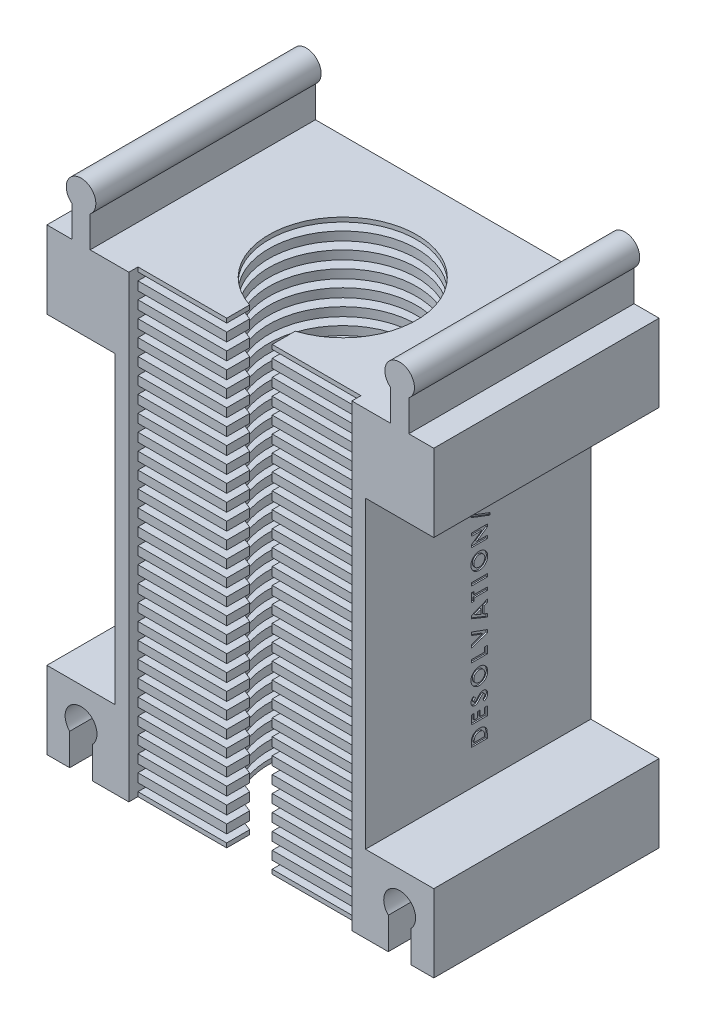
from build123d import *

# Parameters (mm, degrees)
ESQUISSE1_W              = 55
ESQUISSE1_H              = 106.55
BOSS_EXTRU_2_DEPTH       = 49.5
ESQUISSE6_W              = 49
ESQUISSE6_H              = 101.75
ENL_V_MAT_EXTRU_2_DEPTH  = 47
ESQUISSE7_W              = 49
ESQUISSE7_H              = 1.9
BOSS_EXTRU_3_DEPTH       = 45
ESQUISSE8_R              = 16.25
ENL_V_MAT_EXTRU_4_DEPTH  = 107.55
ESQUISSE9_W              = 10
ESQUISSE9_H              = 5.038353904
ENL_V_MAT_EXTRU_5_DEPTH  = 107.55
ESQUISSE11_W             = 55
ESQUISSE11_H             = 49.5
ENL_V_MAT_EXTRU_6_DEPTH  = 4.8
ESQUISSE14_W             = 15
ESQUISSE14_H             = 17.95
BOSS_EXTRU_5_DEPTH       = 49.5
ESQUISSE15_W             = 15
ESQUISSE15_H             = 17.95
BOSS_EXTRU_6_DEPTH       = 49.5
ESQUISSE16_W             = 15
ESQUISSE16_H             = 17
BOSS_EXTRU_7_DEPTH       = 49.5
ESQUISSE17_W             = 15
ESQUISSE17_H             = 17
BOSS_EXTRU_8_DEPTH       = 49.5
ENL_V_MAT_EXTRU_8_DEPTH  = 50.5
BOSS_EXTRU_9_DEPTH       = 49.5
ESQUISSE21_W             = 3.5
ESQUISSE21_H             = 0.628205128
ENL_V_MAT_EXTRU_9_DEPTH  = 0.3
ENL_V_MAT_EXTRU_10_DEPTH = 0.95
ESQUISSE22_W             = 5
ESQUISSE22_H             = 49.5
ENL_V_MAT_EXTRU_11_DEPTH = 0.95


with BuildPart() as part:
    # Esquisse1 → Boss.-Extru.2 (new body)
    with BuildSketch(Plane.XY):
        with Locations((7.352262443, -28.968325792)):
            Rectangle(ESQUISSE1_W, ESQUISSE1_H)
    extrude(amount=BOSS_EXTRU_2_DEPTH)

    # Esquisse6 → Enlèv. mat.-Extru.2 (cut)
    with BuildSketch(Plane.XY.offset(49.5)):
        with Locations((7.352262443, -31.368325792)):
            Rectangle(ESQUISSE6_W, ESQUISSE6_H)
    extrude(amount=-ENL_V_MAT_EXTRU_2_DEPTH, mode=Mode.SUBTRACT)

    # Esquisse7 → Boss.-Extru.3 (add)
    with BuildSketch(Plane.XY.offset(2.5)):
        with Locations((7.352262443, -81.293325792)):
            Rectangle(ESQUISSE7_W, ESQUISSE7_H)
        with Locations((7.352262443, -77.693325792)):
            Rectangle(ESQUISSE7_W, ESQUISSE7_H)
        with Locations((7.352262443, -74.093325792)):
            Rectangle(ESQUISSE7_W, ESQUISSE7_H)
        with Locations((7.352262443, -70.493325792)):
            Rectangle(ESQUISSE7_W, ESQUISSE7_H)
        with Locations((7.352262443, -66.893325792)):
            Rectangle(ESQUISSE7_W, ESQUISSE7_H)
        with Locations((7.352262443, -63.293325792)):
            Rectangle(ESQUISSE7_W, ESQUISSE7_H)
        with Locations((7.352262443, -59.693325792)):
            Rectangle(ESQUISSE7_W, ESQUISSE7_H)
        with Locations((7.352262443, -56.093325792)):
            Rectangle(ESQUISSE7_W, ESQUISSE7_H)
        with Locations((7.352262443, -52.493325792)):
            Rectangle(ESQUISSE7_W, ESQUISSE7_H)
        with Locations((7.352262443, -48.893325792)):
            Rectangle(ESQUISSE7_W, ESQUISSE7_H)
        with Locations((7.352262443, -45.293325792)):
            Rectangle(ESQUISSE7_W, ESQUISSE7_H)
        with Locations((7.352262443, -41.693325792)):
            Rectangle(ESQUISSE7_W, ESQUISSE7_H)
        with Locations((7.352262443, -38.093325792)):
            Rectangle(ESQUISSE7_W, ESQUISSE7_H)
        with Locations((7.352262443, -34.493325792)):
            Rectangle(ESQUISSE7_W, ESQUISSE7_H)
        with Locations((7.352262443, -30.893325792)):
            Rectangle(ESQUISSE7_W, ESQUISSE7_H)
        with Locations((7.352262443, -27.293325792)):
            Rectangle(ESQUISSE7_W, ESQUISSE7_H)
        with Locations((7.352262443, -23.693325792)):
            Rectangle(ESQUISSE7_W, ESQUISSE7_H)
        with Locations((7.352262443, -20.093325792)):
            Rectangle(ESQUISSE7_W, ESQUISSE7_H)
        with Locations((7.352262443, -16.493325792)):
            Rectangle(ESQUISSE7_W, ESQUISSE7_H)
        with Locations((7.352262443, -12.893325792)):
            Rectangle(ESQUISSE7_W, ESQUISSE7_H)
        with Locations((7.352262443, -9.293325792)):
            Rectangle(ESQUISSE7_W, ESQUISSE7_H)
        with Locations((7.352262443, -5.693325792)):
            Rectangle(ESQUISSE7_W, ESQUISSE7_H)
        with Locations((7.352262443, -2.093325792)):
            Rectangle(ESQUISSE7_W, ESQUISSE7_H)
        with Locations((7.352262443, 1.506674208)):
            Rectangle(ESQUISSE7_W, ESQUISSE7_H)
        with Locations((7.352262443, 5.106674208)):
            Rectangle(ESQUISSE7_W, ESQUISSE7_H)
        with Locations((7.352262443, 8.706674208)):
            Rectangle(ESQUISSE7_W, ESQUISSE7_H)
        with Locations((7.352262443, 12.306674208)):
            Rectangle(ESQUISSE7_W, ESQUISSE7_H)
        with Locations((7.352262443, 15.906674208)):
            Rectangle(ESQUISSE7_W, ESQUISSE7_H)
        with Locations((7.352262443, 19.506674208)):
            Rectangle(ESQUISSE7_W, ESQUISSE7_H)
    extrude(amount=BOSS_EXTRU_3_DEPTH)

    # Esquisse8 → Enlèv. mat.-Extru.4 (cut, through all)
    with BuildSketch(Plane.XZ.offset(82.243325792)):
        with Locations((7.352262443, 27)):
            Circle(ESQUISSE8_R)
    extrude(amount=-ENL_V_MAT_EXTRU_4_DEPTH, mode=Mode.SUBTRACT)

    # Esquisse9 → Enlèv. mat.-Extru.5 (cut, through all)
    with BuildSketch(Plane.XZ.offset(82.243325792)):
        with Locations((7.352262443, 44.980823048)):
            Rectangle(ESQUISSE9_W, ESQUISSE9_H)
    extrude(amount=-ENL_V_MAT_EXTRU_5_DEPTH, mode=Mode.SUBTRACT)

    # Esquisse11 → Enlèv. mat.-Extru.6 (cut)
    with BuildSketch(Plane(origin=(0, 24.306674208, 0), x_dir=(1, 0, 0), z_dir=(0, 1, 0))):
        with Locations((7.352262443, -24.75)):
            Rectangle(ESQUISSE11_W, ESQUISSE11_H)
    extrude(amount=-ENL_V_MAT_EXTRU_6_DEPTH, mode=Mode.SUBTRACT)

    # Esquisse14 → Boss.-Extru.5 (add)
    with BuildSketch(Plane.XY.offset(49.5)):
        with Locations((42.352262443, -73.268325792)):
            Rectangle(ESQUISSE14_W, ESQUISSE14_H)
    extrude(amount=-BOSS_EXTRU_5_DEPTH)

    # Esquisse15 → Boss.-Extru.6 (add)
    with BuildSketch(Plane.XY.offset(49.5)):
        with Locations((-27.647737557, -73.268325792)):
            Rectangle(ESQUISSE15_W, ESQUISSE15_H)
    extrude(amount=-BOSS_EXTRU_6_DEPTH)

    # Esquisse16 → Boss.-Extru.7 (add)
    with BuildSketch(Plane.XY.offset(49.5)):
        with Locations((42.352262443, 11.006674208)):
            Rectangle(ESQUISSE16_W, ESQUISSE16_H)
    extrude(amount=-BOSS_EXTRU_7_DEPTH)

    # Esquisse17 → Boss.-Extru.8 (add)
    with BuildSketch(Plane.XY.offset(49.5)):
        with Locations((-27.647737557, 11.006674208)):
            Rectangle(ESQUISSE17_W, ESQUISSE17_H)
    extrude(amount=-BOSS_EXTRU_8_DEPTH)

    # Esquisse18 → Enlèv. mat.-Extru.8 (cut, through all)
    with BuildSketch(Plane.XY.offset(49.5)):
        with BuildLine():
            Line((44.852262443, -74.343325792), (44.852262443, -82.243325792))
            Line((44.852262443, -82.243325792), (39.852262443, -82.243325792))
            Line((39.852262443, -82.243325792), (39.852262443, -74.343325792))
            ThreePointArc((39.852262443, -74.343325792), (42.352262443, -68.393836049), (44.852262443, -74.343325792))
        make_face()
        with BuildLine():
            Line((-30.147737557, -82.243325792), (-25.147737557, -82.243325792))
            Line((-25.147737557, -82.243325792), (-25.147737557, -74.343325792))
            ThreePointArc((-25.147737557, -74.343325792), (-27.647737557, -68.393836049), (-30.147737557, -74.343325792))
            Line((-30.147737557, -74.343325792), (-30.147737557, -82.243325792))
        make_face()
    extrude(amount=-ENL_V_MAT_EXTRU_8_DEPTH, mode=Mode.SUBTRACT)

    # Esquisse20 → Boss.-Extru.9 (add)
    with BuildSketch(Plane.XY.offset(49.5)):
        with BuildLine():
            Line((-29.647737557, 26.346674208), (-29.647737557, 19.506674208))
            Line((-29.647737557, 19.506674208), (-25.647737557, 19.506674208))
            Line((-25.647737557, 19.506674208), (-25.647737557, 26.346674208))
            ThreePointArc((-25.647737557, 26.346674208), (-27.647737557, 32.1584119), (-29.647737557, 26.346674208))
        make_face()
        with BuildLine():
            Line((40.352262443, 19.506674208), (40.352262443, 26.346674208))
            ThreePointArc((40.352262443, 26.346674208), (42.352262443, 32.1584119), (44.352262443, 26.346674208))
            Line((44.352262443, 26.346674208), (44.352262443, 19.506674208))
            Line((44.352262443, 19.506674208), (40.352262443, 19.506674208))
        make_face()
    extrude(amount=-BOSS_EXTRU_9_DEPTH)

    # Esquisse21 → Enlèv. mat.-Extru.9 (cut)
    with BuildSketch(Plane(origin=(34.852262443, 0, 0), x_dir=(0, 0, -1), z_dir=(1, 0, 0))):
        with BuildLine():
            Line((-26.25, -56.568966817), (-26.25, -55.777400311))
            add(Edge.make_bspline(
                [(-26.25, -55.777400311), (-26.249578594, -55.715687085), (-26.248764011, -55.59639472), (-26.239233964, -55.423588275), (-26.225241045, -55.262779541), (-26.203820297, -55.114334816), (-26.178974202, -54.977711122), (-26.145644783, -54.853944802), (-26.107640591, -54.742138404), (-26.062804681, -54.641206053), (-26.010558183, -54.549060361), (-25.952352997, -54.461566177), (-25.886064826, -54.378893855), (-25.812970397, -54.299883605), (-25.731733047, -54.225554968), (-25.643698202, -54.154670132), (-25.547589281, -54.088964674), (-25.445710659, -54.026452461), (-25.337630589, -53.969918483), (-25.224269024, -53.920607434), (-25.106355489, -53.87929927), (-24.983764318, -53.845734248), (-24.856902477, -53.818979051), (-24.72551397, -53.800258979), (-24.589720442, -53.788686044), (-24.4976865, -53.787512066), (-24.450921474, -53.786915535)],
                knots=[0, 0, 0, 0, 0.000185117, 0.000357834, 0.000519065, 0.000669183, 0.000807653, 0.000935374, 0.001053334, 0.001161611, 0.001266144, 0.001370762, 0.001476536, 0.001583695, 0.001693351, 0.00180657, 0.001922483, 0.002042366, 0.002164984, 0.002288073, 0.002412914, 0.002539466, 0.002669135, 0.002801605, 0.002937385, 0.003077654, 0.003077654, 0.003077654, 0.003077654], degree=3))
            add(Edge.make_bspline(
                [(-24.450921474, -53.786915535), (-24.384932979, -53.788477575), (-24.255030763, -53.791552542), (-24.064400757, -53.817454346), (-23.881662884, -53.859346333), (-23.708246589, -53.918250271), (-23.545696172, -53.991275386), (-23.396878133, -54.078512063), (-23.262591281, -54.178681211), (-23.143504152, -54.290615844), (-23.04114743, -54.41181382), (-22.953485402, -54.537762852), (-22.884360039, -54.669690389), (-22.840513664, -54.785935833), (-22.813270001, -54.886737915), (-22.797083391, -54.975231737), (-22.782639367, -55.075819688), (-22.769738179, -55.189168755), (-22.761139953, -55.315267782), (-22.755119024, -55.454138111), (-22.750668347, -55.605597536), (-22.75022862, -55.710790215), (-22.75, -55.765481241)],
                knots=[0, 0, 0, 0, 0.000197895, 0.000389568, 0.000575968, 0.000759549, 0.000938093, 0.001109685, 0.001275991, 0.00143967, 0.001598838, 0.001751113, 0.001899136, 0.002044464, 0.002122868, 0.002212109, 0.002314138, 0.002427722, 0.002554253, 0.002693218, 0.002844719, 0.003008787, 0.003008787, 0.003008787, 0.003008787], degree=3))
            Line((-22.75, -55.765481241), (-22.75, -56.568966817))
            Line((-22.75, -56.568966817), (-26.25, -56.568966817))
        make_face()
        with BuildLine():
            Line((-25.621794872, -55.940761689), (-23.378205128, -55.940761689))
            Line((-23.378205128, -55.940761689), (-23.378205128, -55.612636689))
            add(Edge.make_bspline(
                [(-23.378205128, -55.612636689), (-23.378394152, -55.573601622), (-23.378757652, -55.498535563), (-23.383752105, -55.390024754), (-23.391862503, -55.289884036), (-23.403859003, -55.197982239), (-23.418293863, -55.114108086), (-23.436147882, -55.038567527), (-23.457859729, -54.971211673), (-23.483447361, -54.91148508), (-23.512661318, -54.85695602), (-23.546774213, -54.806439255), (-23.584684458, -54.757684422), (-23.627472703, -54.711592604), (-23.674581701, -54.667992226), (-23.726251594, -54.627140464), (-23.782325449, -54.588492273), (-23.843099544, -54.553039619), (-23.907932147, -54.520642798), (-23.976195242, -54.491903186), (-24.04845732, -54.468073807), (-24.124041919, -54.448268286), (-24.20360709, -54.434114996), (-24.286563503, -54.422405848), (-24.373239826, -54.41636944), (-24.432217292, -54.415540981), (-24.462139423, -54.415120664)],
                knots=[0, 0, 0, 0, 0.000117096, 0.00022518, 0.000325793, 0.00041841, 0.000503133, 0.000581017, 0.00065108, 0.000715155, 0.0007757, 0.00083637, 0.000897801, 0.000960813, 0.001024815, 0.001090185, 0.001158251, 0.001228957, 0.001301074, 0.001375555, 0.001450937, 0.001529162, 0.001609745, 0.001693235, 0.001780402, 0.001870171, 0.001870171, 0.001870171, 0.001870171], degree=3))
            add(Edge.make_bspline(
                [(-24.462139423, -54.415120664), (-24.507993301, -54.415954791), (-24.597404811, -54.417581276), (-24.727617239, -54.433364792), (-24.850078276, -54.458796641), (-24.964473331, -54.495843815), (-25.071529664, -54.541402153), (-25.169867721, -54.599330531), (-25.261099367, -54.666109794), (-25.314608967, -54.718947546), (-25.341346154, -54.745349029)],
                knots=[0, 0, 0, 0, 0.000137507, 0.000268129, 0.000392852, 0.000512141, 0.000628325, 0.00074112, 0.000853862, 0.000966454, 0.000966454, 0.000966454, 0.000966454], degree=3))
            add(Edge.make_bspline(
                [(-25.341346154, -54.745349029), (-25.364130624, -54.771381223), (-25.410665325, -54.824549032), (-25.466425797, -54.917894233), (-25.515416837, -55.020755809), (-25.554261268, -55.135486926), (-25.584981101, -55.260978759), (-25.606167818, -55.397978738), (-25.619782177, -55.5457532), (-25.6211096, -55.648127904), (-25.621794872, -55.700978035)],
                knots=[0, 0, 0, 0, 0.000103595, 0.000211582, 0.000324802, 0.000444978, 0.000574215, 0.000711958, 0.000860493, 0.001019003, 0.001019003, 0.001019003, 0.001019003], degree=3))
            Line((-25.621794872, -55.700978035), (-25.621794872, -55.940761689))
        make_face(mode=Mode.SUBTRACT)
        Polygon((-26.25, -52.270248869), (-26.25, -50.385633484), (-25.621794872, -50.385633484), (-25.621794872, -51.642043741), (-24.948717949, -51.642043741), (-24.948717949, -50.385633484), (-24.320512821, -50.385633484), (-24.320512821, -51.642043741), (-23.378205128, -51.642043741), (-23.378205128, -50.385633484), (-22.75, -50.385633484), (-22.75, -52.270248869), align=None)
        with BuildLine():
            Line((-25.782351763, -47.074095023), (-25.352564103, -47.543846625))
            add(Edge.make_bspline(
                [(-25.352564103, -47.543846625), (-25.380948479, -47.56396877), (-25.435442524, -47.602600481), (-25.508411334, -47.665218455), (-25.57065916, -47.727553677), (-25.621925958, -47.790183645), (-25.661900244, -47.853663487), (-25.690202481, -47.91788301), (-25.708194481, -47.982478138), (-25.710434918, -48.025876092), (-25.711538462, -48.047252074)],
                knots=[0, 0, 0, 0, 0.000104333, 0.000200305, 0.000288057, 0.000368319, 0.000442638, 0.000512332, 0.000578316, 0.000642364, 0.000642364, 0.000642364, 0.000642364], degree=3))
            add(Edge.make_bspline(
                [(-25.711538462, -48.047252074), (-25.710859996, -48.067200818), (-25.709550059, -48.105716602), (-25.695874155, -48.160367956), (-25.673774631, -48.20948143), (-25.643247665, -48.251748774), (-25.606789609, -48.285751934), (-25.567978229, -48.312191421), (-25.525661045, -48.327555458), (-25.49663918, -48.329528504), (-25.482271635, -48.330505279)],
                knots=[0, 0, 0, 0, 5.9744e-05, 0.000115349, 0.000167746, 0.00022048, 0.000270574, 0.000316662, 0.00036057, 0.000403619, 0.000403619, 0.000403619, 0.000403619], degree=3))
            add(Edge.make_bspline(
                [(-25.482271635, -48.330505279), (-25.467703647, -48.329886982), (-25.438365745, -48.328641817), (-25.395367395, -48.316615224), (-25.353353002, -48.298487713), (-25.327776842, -48.281166136), (-25.314703526, -48.27231217)],
                knots=[0, 0, 0, 0, 4.3611e-05, 8.7826e-05, 0.000133031, 0.000180298, 0.000180298, 0.000180298, 0.000180298], degree=3))
            add(Edge.make_bspline(
                [(-25.314703526, -48.27231217), (-25.304570777, -48.264231681), (-25.281111756, -48.245523987), (-25.243396348, -48.21090352), (-25.198817605, -48.165697453), (-25.146449278, -48.111029204), (-25.085794161, -48.047089481), (-25.017865448, -47.972886999), (-24.943323803, -47.887879603), (-24.890772321, -47.828255945), (-24.86318109, -47.796951593)],
                knots=[0, 0, 0, 0, 3.8873e-05, 8.9997e-05, 0.000153455, 0.000229322, 0.000317108, 0.000417848, 0.000531096, 0.000656281, 0.000656281, 0.000656281, 0.000656281], degree=3))
            add(Edge.make_bspline(
                [(-24.86318109, -47.796951593), (-24.837708176, -47.767503382), (-24.789365877, -47.711616794), (-24.720638911, -47.632202055), (-24.659084447, -47.561955316), (-24.604241548, -47.501515443), (-24.558368712, -47.449076348), (-24.51864378, -47.406957294), (-24.486804547, -47.373355671), (-24.467551594, -47.354273887), (-24.459334936, -47.346130279)],
                knots=[0, 0, 0, 0, 0.00011681, 0.000221681, 0.000315075, 0.000396998, 0.000466519, 0.000524062, 0.000570675, 0.000605379, 0.000605379, 0.000605379, 0.000605379], degree=3))
            add(Edge.make_bspline(
                [(-24.459334936, -47.346130279), (-24.425893407, -47.31523371), (-24.361607045, -47.255839654), (-24.262008623, -47.17860103), (-24.164866042, -47.115310748), (-24.068591755, -47.06577726), (-23.970962887, -47.028711575), (-23.869873927, -47.002743909), (-23.764557336, -46.986955273), (-23.692829706, -46.985226056), (-23.656550481, -46.984351433)],
                knots=[0, 0, 0, 0, 0.000136539, 0.000262476, 0.000377607, 0.000483905, 0.000586645, 0.000690207, 0.000796501, 0.000905285, 0.000905285, 0.000905285, 0.000905285], degree=3))
            add(Edge.make_bspline(
                [(-23.656550481, -46.984351433), (-23.62120206, -46.984977938), (-23.551847141, -46.986207165), (-23.450356547, -47.001262831), (-23.353225654, -47.022731334), (-23.261511331, -47.055925385), (-23.173708316, -47.096382164), (-23.091183556, -47.14710033), (-23.013104683, -47.206662795), (-22.940856727, -47.27492696), (-22.87532825, -47.350448565), (-22.816876988, -47.43140365), (-22.76900145, -47.518893919), (-22.728000136, -47.611176844), (-22.698822842, -47.709937255), (-22.675868152, -47.813375185), (-22.662419885, -47.922565757), (-22.660987959, -47.997202332), (-22.66025641, -48.035333003)],
                knots=[0, 0, 0, 0, 0.000105953, 0.000207884, 0.000307206, 0.000403889, 0.000499869, 0.000596786, 0.000693825, 0.000794014, 0.0008944, 0.000993427, 0.001092919, 0.001193084, 0.001295767, 0.001401245, 0.001510733, 0.001625093, 0.001625093, 0.001625093, 0.001625093], degree=3))
            add(Edge.make_bspline(
                [(-22.66025641, -48.035333003), (-22.660787067, -48.065267424), (-22.661838073, -48.124554745), (-22.670430813, -48.211932456), (-22.684268419, -48.296316378), (-22.704207169, -48.377560965), (-22.729126286, -48.456301852), (-22.76093787, -48.531771488), (-22.797508368, -48.604512241), (-22.839623573, -48.674374584), (-22.888564784, -48.740917968), (-22.94241612, -48.806007246), (-23.003786402, -48.867498389), (-23.071484125, -48.926769458), (-23.145924483, -48.983055602), (-23.225977896, -49.038278515), (-23.31315656, -49.089961723), (-23.374312024, -49.121889558), (-23.405548878, -49.138197587)],
                knots=[0, 0, 0, 0, 8.9787e-05, 0.000177831, 0.000263126, 0.00034611, 0.000428593, 0.000510624, 0.000591521, 0.000672684, 0.000755006, 0.00083912, 0.000925881, 0.001015317, 0.001108851, 0.001205697, 0.00130694, 0.001412645, 0.001412645, 0.001412645, 0.001412645], degree=3))
            Line((-23.405548878, -49.138197587), (-23.737179487, -48.585713612))
            add(Edge.make_bspline(
                [(-23.737179487, -48.585713612), (-23.701721473, -48.565314802), (-23.63374543, -48.526208538), (-23.542411001, -48.459939319), (-23.464198182, -48.392049887), (-23.400489388, -48.3209707), (-23.350432751, -48.247566053), (-23.314658806, -48.171481385), (-23.292514774, -48.092663241), (-23.289810476, -48.038975902), (-23.288461538, -48.012195984)],
                knots=[0, 0, 0, 0, 0.000122646, 0.000235123, 0.000337949, 0.000432798, 0.000520693, 0.0006035, 0.000684117, 0.000764351, 0.000764351, 0.000764351, 0.000764351], degree=3))
            add(Edge.make_bspline(
                [(-23.288461538, -48.012195984), (-23.289563154, -47.984956973), (-23.291700449, -47.932109325), (-23.311441996, -47.856676069), (-23.342437673, -47.787516005), (-23.38666423, -47.727734556), (-23.437708399, -47.677115394), (-23.494497371, -47.639755546), (-23.555941668, -47.616285839), (-23.598624918, -47.613804521), (-23.620092147, -47.612556561)],
                knots=[0, 0, 0, 0, 8.1575e-05, 0.000158267, 0.000232307, 0.000307618, 0.000380007, 0.000446905, 0.00051034, 0.000574526, 0.000574526, 0.000574526, 0.000574526], degree=3))
            add(Edge.make_bspline(
                [(-23.620092147, -47.612556561), (-23.640063911, -47.613709001), (-23.680634636, -47.616050074), (-23.74095678, -47.633293689), (-23.801251492, -47.66025072), (-23.850706845, -47.692142789), (-23.892114472, -47.724596963), (-23.927992307, -47.755630472), (-23.967631034, -47.793421078), (-24.011080516, -47.837872959), (-24.058723248, -47.88839879), (-24.110554566, -47.945041133), (-24.166117898, -48.008448602), (-24.20396709, -48.053265126), (-24.223758013, -48.076699189)],
                knots=[0, 0, 0, 0, 5.9859e-05, 0.000121597, 0.000186877, 0.000257482, 0.000297452, 0.000344677, 0.000399728, 0.000461701, 0.000531137, 0.000608059, 0.000692021, 0.000784039, 0.000784039, 0.000784039, 0.000784039], degree=3))
            add(Edge.make_bspline(
                [(-24.223758013, -48.076699189), (-24.261450785, -48.121248313), (-24.333794625, -48.206751566), (-24.440644621, -48.327577916), (-24.540504245, -48.436455362), (-24.634614437, -48.532434437), (-24.721216561, -48.616767369), (-24.801079437, -48.688790932), (-24.874765535, -48.748119143), (-24.962626851, -48.809701418), (-25.0687399, -48.868922242), (-25.196325337, -48.920201939), (-25.324023034, -48.953158574), (-25.4098701, -48.956879161), (-25.452123397, -48.958710407)],
                knots=[0, 0, 0, 0, 0.000175062, 0.000335996, 0.000483855, 0.000618216, 0.0007392, 0.000846451, 0.000940727, 0.001022807, 0.00116813, 0.001304054, 0.001434653, 0.001561236, 0.001561236, 0.001561236, 0.001561236], degree=3))
            add(Edge.make_bspline(
                [(-25.452123397, -48.958710407), (-25.482088506, -48.957951198), (-25.54112299, -48.956455475), (-25.627924828, -48.943113858), (-25.711680407, -48.923173207), (-25.792088406, -48.894217673), (-25.86903224, -48.856622348), (-25.94294889, -48.811018754), (-26.013062404, -48.756339157), (-26.080062459, -48.695502211), (-26.140663498, -48.627665077), (-26.194122447, -48.55547558), (-26.239518366, -48.479250328), (-26.275959011, -48.398695632), (-26.304885676, -48.314469448), (-26.325149965, -48.226358987), (-26.337265806, -48.134529777), (-26.338907372, -48.072062067), (-26.33974359, -48.040240856)],
                knots=[0, 0, 0, 0, 8.9842e-05, 0.000176999, 0.000262874, 0.000347814, 0.000432791, 0.000519374, 0.000607862, 0.00069917, 0.000790526, 0.000880272, 0.00096829, 0.00105614, 0.00114505, 0.001235018, 0.00132694, 0.001422385, 0.001422385, 0.001422385, 0.001422385], degree=3))
            add(Edge.make_bspline(
                [(-26.33974359, -48.040240856), (-26.338235058, -47.999002941), (-26.335229901, -47.916852628), (-26.311729417, -47.795391603), (-26.274775458, -47.676751209), (-26.230185096, -47.581156052), (-26.187011968, -47.50507503), (-26.147199435, -47.446819861), (-26.101765707, -47.387195621), (-26.049430261, -47.327125219), (-25.991909725, -47.265150458), (-25.927878206, -47.20218695), (-25.857994416, -47.137563989), (-25.808007695, -47.095621971), (-25.782351763, -47.074095023)],
                knots=[0, 0, 0, 0, 0.000123638, 0.0002463, 0.000369811, 0.000495611, 0.000561878, 0.000632077, 0.000707101, 0.000786646, 0.000870979, 0.000960715, 0.001055985, 0.001156444, 0.001156444, 0.001156444, 0.001156444], degree=3))
        make_face()
        with BuildLine():
            add(Edge.make_bspline(
                [(-26.33974359, -43.822853035), (-26.338167721, -43.762001434), (-26.3350566, -43.641866592), (-26.309132442, -43.465188325), (-26.266869189, -43.294938823), (-26.208203575, -43.13113496), (-26.131234536, -42.974520936), (-26.039491395, -42.823570349), (-25.928986383, -42.680195073), (-25.803655216, -42.544890444), (-25.667274317, -42.419884252), (-25.520441097, -42.311593951), (-25.366840026, -42.21899487), (-25.205888991, -42.142814829), (-25.037039251, -42.084298219), (-24.860994412, -42.043414326), (-24.677706796, -42.017114909), (-24.552909074, -42.014092592), (-24.489483173, -42.012556561)],
                knots=[0, 0, 0, 0, 0.000182486, 0.000360268, 0.000534396, 0.00070805, 0.00088114, 0.00105706, 0.001237116, 0.001423178, 0.0016098, 0.001791254, 0.001969572, 0.002147089, 0.002324474, 0.002504569, 0.0026886, 0.00287879, 0.00287879, 0.00287879, 0.00287879], degree=3))
            add(Edge.make_bspline(
                [(-24.489483173, -42.012556561), (-24.426772131, -42.014192899), (-24.30319801, -42.017417355), (-24.121596661, -42.042335582), (-23.947447913, -42.083934104), (-23.780397792, -42.141298905), (-23.621288648, -42.216230374), (-23.469456335, -42.307245168), (-23.325421581, -42.415302063), (-23.189791309, -42.537812006), (-23.06584061, -42.671849774), (-22.95732277, -42.814611152), (-22.86539022, -42.964394772), (-22.789684465, -43.121083325), (-22.73257561, -43.285805914), (-22.689870401, -43.456703157), (-22.665166628, -43.635165027), (-22.66190961, -43.756405724), (-22.66025641, -43.817945183)],
                knots=[0, 0, 0, 0, 0.000188089, 0.000370635, 0.000548684, 0.000724515, 0.000899532, 0.001075324, 0.001254672, 0.001438843, 0.001622923, 0.001801572, 0.00197593, 0.002149347, 0.002322529, 0.002498019, 0.002677092, 0.002861679, 0.002861679, 0.002861679, 0.002861679], degree=3))
            add(Edge.make_bspline(
                [(-22.66025641, -43.817945183), (-22.66172221, -43.882312928), (-22.664602305, -44.00878675), (-22.691759654, -44.1939277), (-22.733164649, -44.371055921), (-22.793109119, -44.539686079), (-22.870998612, -44.699687081), (-22.965044231, -44.851776466), (-23.077062596, -44.994810385), (-23.203675043, -45.128312064), (-23.342252759, -45.249250819), (-23.488638503, -45.356006675), (-23.641725246, -45.446056684), (-23.801581713, -45.51940547), (-23.967215196, -45.577230646), (-24.13963425, -45.618019753), (-24.318425406, -45.642114848), (-24.439863931, -45.645471155), (-24.501402244, -45.647171946)],
                knots=[0, 0, 0, 0, 0.000192992, 0.000379203, 0.000560143, 0.000737993, 0.000914849, 0.001093067, 0.001273424, 0.001458907, 0.001644244, 0.001824454, 0.002001698, 0.002176124, 0.002351292, 0.002527132, 0.002706806, 0.002891392, 0.002891392, 0.002891392, 0.002891392], degree=3))
            add(Edge.make_bspline(
                [(-24.501402244, -45.647171946), (-24.542801939, -45.646637984), (-24.625077116, -45.64557682), (-24.747005781, -45.632800024), (-24.866550437, -45.61439328), (-24.983253879, -45.58721462), (-25.098077566, -45.553983661), (-25.209998546, -45.511492182), (-25.31977582, -45.46250229), (-25.426179008, -45.405860667), (-25.527982507, -45.34182707), (-25.626061507, -45.273445763), (-25.717849216, -45.198112983), (-25.804324601, -45.117368295), (-25.885156419, -45.030941799), (-25.960260646, -44.938659263), (-26.030496839, -44.841183532), (-26.094932582, -44.738505642), (-26.151890013, -44.631385042), (-26.202895691, -44.522185532), (-26.244766818, -44.410453326), (-26.279240778, -44.29684322), (-26.306944788, -44.18151578), (-26.325356866, -44.063554362), (-26.338128579, -43.943961559), (-26.339203975, -43.863318348), (-26.33974359, -43.822853035)],
                knots=[0, 0, 0, 0, 0.000124148, 0.000246724, 0.000367409, 0.000486805, 0.000605941, 0.000725748, 0.00084563, 0.000966388, 0.001087007, 0.001206249, 0.001324841, 0.0014429, 0.001560959, 0.001679551, 0.001799606, 0.001921192, 0.002042899, 0.002163361, 0.002282513, 0.002400505, 0.002519378, 0.002637986, 0.002758469, 0.002879813, 0.002879813, 0.002879813, 0.002879813], degree=3))
        make_face()
        with BuildLine():
            add(Edge.make_bspline(
                [(-25.711538462, -43.832668741), (-25.710439594, -43.873621987), (-25.708270869, -43.954447307), (-25.691748119, -44.073003332), (-25.66535941, -44.186821303), (-25.627135687, -44.295270281), (-25.578486588, -44.398820295), (-25.5195821, -44.497654906), (-25.448397447, -44.590405459), (-25.368754215, -44.678308693), (-25.280013352, -44.757714801), (-25.184912425, -44.827872602), (-25.083610251, -44.886583381), (-24.977047904, -44.935754027), (-24.864027118, -44.972768625), (-24.745433197, -44.999133013), (-24.621061798, -45.015794323), (-24.536277978, -45.017894501), (-24.492988782, -45.018966817)],
                knots=[0, 0, 0, 0, 0.000122824, 0.000242406, 0.000358388, 0.000472807, 0.000586661, 0.000701131, 0.000817238, 0.000936842, 0.001056496, 0.001173871, 0.001290754, 0.001407153, 0.001525327, 0.001646775, 0.001771221, 0.00190105, 0.00190105, 0.00190105, 0.00190105], degree=3))
            add(Edge.make_bspline(
                [(-24.492988782, -45.018966817), (-24.445016002, -45.017541828), (-24.350997301, -45.014749085), (-24.213821902, -44.995189856), (-24.084150974, -44.961427616), (-23.962628361, -44.913548335), (-23.848569642, -44.852866041), (-23.742617566, -44.778538736), (-23.64427387, -44.690578429), (-23.586841652, -44.622852092), (-23.557692308, -44.588478035)],
                knots=[0, 0, 0, 0, 0.000143901, 0.000282022, 0.000414667, 0.000544995, 0.00067297, 0.000801345, 0.000932411, 0.001067493, 0.001067493, 0.001067493, 0.001067493], degree=3))
            add(Edge.make_bspline(
                [(-23.557692308, -44.588478035), (-23.536158968, -44.560316757), (-23.493577439, -44.504628678), (-23.439000474, -44.41573838), (-23.392222571, -44.324198877), (-23.354426578, -44.229319388), (-23.324696886, -44.131300293), (-23.303877671, -44.030155034), (-23.290811814, -43.926026926), (-23.289250196, -43.855610619), (-23.288461538, -43.820048548)],
                knots=[0, 0, 0, 0, 0.000106293, 0.000210192, 0.000312412, 0.000414354, 0.000516162, 0.000619291, 0.000723822, 0.000830475, 0.000830475, 0.000830475, 0.000830475], degree=3))
            add(Edge.make_bspline(
                [(-23.288461538, -43.820048548), (-23.289571354, -43.779800318), (-23.291754951, -43.70061066), (-23.308051007, -43.584249849), (-23.335754907, -43.472827233), (-23.373360596, -43.365296451), (-23.423815369, -43.263147933), (-23.483422698, -43.164756684), (-23.555069551, -43.071837973), (-23.636390935, -42.984425718), (-23.725443642, -42.904248434), (-23.820575808, -42.833516927), (-23.920902252, -42.773840352), (-24.026406378, -42.72504465), (-24.136972237, -42.686821477), (-24.25293853, -42.660723853), (-24.373776907, -42.643935536), (-24.456006023, -42.641832868), (-24.497896635, -42.640761689)],
                knots=[0, 0, 0, 0, 0.000120723, 0.000237527, 0.000351629, 0.000464725, 0.000578551, 0.000692784, 0.000809316, 0.00092987, 0.001050514, 0.001168305, 0.00128494, 0.001400065, 0.00151647, 0.001635184, 0.001756155, 0.001881781, 0.001881781, 0.001881781, 0.001881781], degree=3))
            add(Edge.make_bspline(
                [(-24.497896635, -42.640761689), (-24.539547888, -42.641866123), (-24.621532028, -42.644040033), (-24.742037961, -42.660428234), (-24.857356876, -42.68767306), (-24.967786038, -42.726178708), (-25.07390519, -42.774148733), (-25.17479331, -42.83440707), (-25.270363111, -42.90564759), (-25.360046419, -42.986567956), (-25.442465159, -43.074630313), (-25.513988235, -43.169177871), (-25.576139881, -43.267560561), (-25.624826882, -43.372036945), (-25.663615736, -43.480469217), (-25.692180398, -43.593519118), (-25.708154796, -43.711614809), (-25.710400519, -43.791957751), (-25.711538462, -43.832668741)],
                knots=[0, 0, 0, 0, 0.000124926, 0.000245897, 0.000364088, 0.00047983, 0.000596229, 0.000712864, 0.000831635, 0.000953269, 0.001074815, 0.001192886, 0.001308453, 0.00142324, 0.001537892, 0.001653524, 0.001772411, 0.001894535, 0.001894535, 0.001894535, 0.001894535], degree=3))
        make_face(mode=Mode.SUBTRACT)
        Polygon((-26.25, -40.495889894), (-26.25, -39.867684766), (-23.378205128, -39.867684766), (-23.378205128, -38.880505279), (-22.75, -38.880505279), (-22.75, -40.495889894), align=None)
        Polygon((-26.25, -37.745248869), (-26.25, -37.074275311), (-23.763822115, -36.174736048), (-26.25, -35.27309342), (-26.25, -34.604223228), (-22.75, -35.873253676), (-22.75, -36.478321785), align=None)
        Polygon((-26.25, -32.077240055), (-26.25, -31.494607843), (-22.75, -30.081146305), (-22.75, -30.752119862), (-23.467948718, -31.024155119), (-23.467948718, -32.549095023), (-22.75, -32.821130279), (-22.75, -33.491402715), align=None)
        Polygon((-25.311197917, -31.78627451), (-24.096153846, -32.310713612), (-24.096153846, -31.261835407), align=None, mode=Mode.SUBTRACT)
        Polygon((-26.25, -29.035633484), (-26.25, -27.1510181), (-25.621794872, -27.1510181), (-25.621794872, -27.779223228), (-22.75, -27.779223228), (-22.75, -28.407428356), (-25.621794872, -28.407428356), (-25.621794872, -29.035633484), align=None)
        with Locations((-24.5, -25.544607843)):
            Rectangle(ESQUISSE21_W, ESQUISSE21_H)
        with BuildLine():
            add(Edge.make_bspline(
                [(-26.33974359, -21.889519702), (-26.338167721, -21.828668101), (-26.3350566, -21.708533258), (-26.309132442, -21.531854992), (-26.266869189, -21.36160549), (-26.208203575, -21.197801627), (-26.131234536, -21.041187603), (-26.039491395, -20.890237016), (-25.928986383, -20.74686174), (-25.803655216, -20.611557111), (-25.667274317, -20.486550918), (-25.520441097, -20.378260618), (-25.366840026, -20.285661537), (-25.205888991, -20.209481496), (-25.037039251, -20.150964886), (-24.860994412, -20.110080992), (-24.677706796, -20.083781576), (-24.552909074, -20.080759259), (-24.489483173, -20.079223228)],
                knots=[0, 0, 0, 0, 0.000182486, 0.000360268, 0.000534396, 0.00070805, 0.00088114, 0.00105706, 0.001237116, 0.001423178, 0.0016098, 0.001791254, 0.001969572, 0.002147089, 0.002324474, 0.002504569, 0.0026886, 0.00287879, 0.00287879, 0.00287879, 0.00287879], degree=3))
            add(Edge.make_bspline(
                [(-24.489483173, -20.079223228), (-24.426772131, -20.080859566), (-24.30319801, -20.084084022), (-24.121596661, -20.109002249), (-23.947447913, -20.150600771), (-23.780397792, -20.207965572), (-23.621288648, -20.28289704), (-23.469456335, -20.373911835), (-23.325421581, -20.481968729), (-23.189791309, -20.604478673), (-23.06584061, -20.738516441), (-22.95732277, -20.881277818), (-22.86539022, -21.031061438), (-22.789684465, -21.187749992), (-22.73257561, -21.352472581), (-22.689870401, -21.523369824), (-22.665166628, -21.701831693), (-22.66190961, -21.82307239), (-22.66025641, -21.88461185)],
                knots=[0, 0, 0, 0, 0.000188089, 0.000370635, 0.000548684, 0.000724515, 0.000899532, 0.001075324, 0.001254672, 0.001438843, 0.001622923, 0.001801572, 0.00197593, 0.002149347, 0.002322529, 0.002498019, 0.002677092, 0.002861679, 0.002861679, 0.002861679, 0.002861679], degree=3))
            add(Edge.make_bspline(
                [(-22.66025641, -21.88461185), (-22.66172221, -21.948979595), (-22.664602305, -22.075453417), (-22.691759654, -22.260594366), (-22.733164649, -22.437722588), (-22.793109119, -22.606352745), (-22.870998612, -22.766353748), (-22.965044231, -22.918443132), (-23.077062596, -23.061477051), (-23.203675043, -23.19497873), (-23.342252759, -23.315917486), (-23.488638503, -23.422673342), (-23.641725246, -23.512723351), (-23.801581713, -23.586072137), (-23.967215196, -23.643897313), (-24.13963425, -23.68468642), (-24.318425406, -23.708781515), (-24.439863931, -23.712137822), (-24.501402244, -23.713838612)],
                knots=[0, 0, 0, 0, 0.000192992, 0.000379203, 0.000560143, 0.000737993, 0.000914849, 0.001093067, 0.001273424, 0.001458907, 0.001644244, 0.001824454, 0.002001698, 0.002176124, 0.002351292, 0.002527132, 0.002706806, 0.002891392, 0.002891392, 0.002891392, 0.002891392], degree=3))
            add(Edge.make_bspline(
                [(-24.501402244, -23.713838612), (-24.542801939, -23.71330465), (-24.625077116, -23.712243487), (-24.747005781, -23.699466691), (-24.866550437, -23.681059946), (-24.983253879, -23.653881286), (-25.098077566, -23.620650328), (-25.209998546, -23.578158849), (-25.31977582, -23.529168957), (-25.426179008, -23.472527334), (-25.527982507, -23.408493737), (-25.626061507, -23.34011243), (-25.717849216, -23.26477965), (-25.804324601, -23.184034962), (-25.885156419, -23.097608466), (-25.960260646, -23.00532593), (-26.030496839, -22.907850198), (-26.094932582, -22.805172309), (-26.151890013, -22.698051708), (-26.202895691, -22.588852199), (-26.244766818, -22.477119992), (-26.279240778, -22.363509887), (-26.306944788, -22.248182447), (-26.325356866, -22.130221029), (-26.338128579, -22.010628226), (-26.339203975, -21.929985015), (-26.33974359, -21.889519702)],
                knots=[0, 0, 0, 0, 0.000124148, 0.000246724, 0.000367409, 0.000486805, 0.000605941, 0.000725748, 0.00084563, 0.000966388, 0.001087007, 0.001206249, 0.001324841, 0.0014429, 0.001560959, 0.001679551, 0.001799606, 0.001921192, 0.002042899, 0.002163361, 0.002282513, 0.002400505, 0.002519378, 0.002637986, 0.002758469, 0.002879813, 0.002879813, 0.002879813, 0.002879813], degree=3))
        make_face()
        with BuildLine():
            add(Edge.make_bspline(
                [(-25.711538462, -21.899335407), (-25.710439594, -21.940288654), (-25.708270869, -22.021113974), (-25.691748119, -22.139669999), (-25.66535941, -22.253487969), (-25.627135687, -22.361936948), (-25.578486588, -22.465486962), (-25.5195821, -22.564321573), (-25.448397447, -22.657072126), (-25.368754215, -22.74497536), (-25.280013352, -22.824381468), (-25.184912425, -22.894539269), (-25.083610251, -22.953250048), (-24.977047904, -23.002420693), (-24.864027118, -23.039435291), (-24.745433197, -23.06579968), (-24.621061798, -23.082460989), (-24.536277978, -23.084561168), (-24.492988782, -23.085633484)],
                knots=[0, 0, 0, 0, 0.000122824, 0.000242406, 0.000358388, 0.000472807, 0.000586661, 0.000701131, 0.000817238, 0.000936842, 0.001056496, 0.001173871, 0.001290754, 0.001407153, 0.001525327, 0.001646775, 0.001771221, 0.00190105, 0.00190105, 0.00190105, 0.00190105], degree=3))
            add(Edge.make_bspline(
                [(-24.492988782, -23.085633484), (-24.445016002, -23.084208495), (-24.350997301, -23.081415751), (-24.213821902, -23.061856523), (-24.084150974, -23.028094283), (-23.962628361, -22.980215002), (-23.848569642, -22.919532708), (-23.742617566, -22.845205402), (-23.64427387, -22.757245096), (-23.586841652, -22.689518759), (-23.557692308, -22.655144702)],
                knots=[0, 0, 0, 0, 0.000143901, 0.000282022, 0.000414667, 0.000544995, 0.00067297, 0.000801345, 0.000932411, 0.001067493, 0.001067493, 0.001067493, 0.001067493], degree=3))
            add(Edge.make_bspline(
                [(-23.557692308, -22.655144702), (-23.536158968, -22.626983424), (-23.493577439, -22.571295345), (-23.439000474, -22.482405047), (-23.392222571, -22.390865544), (-23.354426578, -22.295986054), (-23.324696886, -22.19796696), (-23.303877671, -22.096821701), (-23.290811814, -21.992693593), (-23.289250196, -21.922277286), (-23.288461538, -21.886715215)],
                knots=[0, 0, 0, 0, 0.000106293, 0.000210192, 0.000312412, 0.000414354, 0.000516162, 0.000619291, 0.000723822, 0.000830475, 0.000830475, 0.000830475, 0.000830475], degree=3))
            add(Edge.make_bspline(
                [(-23.288461538, -21.886715215), (-23.289571354, -21.846466985), (-23.291754951, -21.767277327), (-23.308051007, -21.650916516), (-23.335754907, -21.539493899), (-23.373360596, -21.431963118), (-23.423815369, -21.3298146), (-23.483422698, -21.231423351), (-23.555069551, -21.138504639), (-23.636390935, -21.051092384), (-23.725443642, -20.970915101), (-23.820575808, -20.900183594), (-23.920902252, -20.840507018), (-24.026406378, -20.791711317), (-24.136972237, -20.753488143), (-24.25293853, -20.72739052), (-24.373776907, -20.710602202), (-24.456006023, -20.708499534), (-24.497896635, -20.707428356)],
                knots=[0, 0, 0, 0, 0.000120723, 0.000237527, 0.000351629, 0.000464725, 0.000578551, 0.000692784, 0.000809316, 0.00092987, 0.001050514, 0.001168305, 0.00128494, 0.001400065, 0.00151647, 0.001635184, 0.001756155, 0.001881781, 0.001881781, 0.001881781, 0.001881781], degree=3))
            add(Edge.make_bspline(
                [(-24.497896635, -20.707428356), (-24.539547888, -20.70853279), (-24.621532028, -20.710706699), (-24.742037961, -20.7270949), (-24.857356876, -20.754339727), (-24.967786038, -20.792845375), (-25.07390519, -20.840815399), (-25.17479331, -20.901073737), (-25.270363111, -20.972314256), (-25.360046419, -21.053234622), (-25.442465159, -21.141296979), (-25.513988235, -21.235844538), (-25.576139881, -21.334227228), (-25.624826882, -21.438703612), (-25.663615736, -21.547135883), (-25.692180398, -21.660185784), (-25.708154796, -21.778281476), (-25.710400519, -21.858624417), (-25.711538462, -21.899335407)],
                knots=[0, 0, 0, 0, 0.000124926, 0.000245897, 0.000364088, 0.00047983, 0.000596229, 0.000712864, 0.000831635, 0.000953269, 0.001074815, 0.001192886, 0.001308453, 0.00142324, 0.001537892, 0.001653524, 0.001772411, 0.001894535, 0.001894535, 0.001894535, 0.001894535], degree=3))
        make_face(mode=Mode.SUBTRACT)
        Polygon((-26.25, -18.562556561), (-26.25, -17.996751273), (-23.946814904, -16.408710407), (-26.25, -16.408710407), (-26.25, -15.780505279), (-22.75, -15.780505279), (-22.75, -16.350517298), (-25.046173878, -17.934351433), (-22.75, -17.934351433), (-22.75, -18.562556561), align=None)
        Polygon((-22.121794872, -14.398453997), (-26.33974359, -12.787977234), (-26.33974359, -12.311915535), (-22.121794872, -13.922392298), align=None)
        with BuildLine():
            Line((-25.083333333, -10.548453997), (-25.083333333, -11.176659125))
            add(Edge.make_bspline(
                [(-25.083333333, -11.176659125), (-25.130854225, -11.173947069), (-25.223707194, -11.168647873), (-25.358570766, -11.147545894), (-25.486033191, -11.11934262), (-25.605711269, -11.081380317), (-25.717655278, -11.034621225), (-25.821494412, -10.977901564), (-25.917972725, -10.91291478), (-26.00539818, -10.838350943), (-26.083996324, -10.757236239), (-26.152708884, -10.669778617), (-26.210230283, -10.576226513), (-26.257415349, -10.477205488), (-26.295169479, -10.373104486), (-26.320397882, -10.262871713), (-26.337486499, -10.14747983), (-26.33898158, -10.06848404), (-26.33974359, -10.028221625)],
                knots=[0, 0, 0, 0, 0.000142716, 0.000278858, 0.000408976, 0.000534035, 0.000655007, 0.000772346, 0.00088844, 0.001003349, 0.001116402, 0.001226781, 0.001336329, 0.001445148, 0.001555367, 0.001667776, 0.001783885, 0.001904578, 0.001904578, 0.001904578, 0.001904578], degree=3))
            add(Edge.make_bspline(
                [(-26.33974359, -10.028221625), (-26.338305172, -9.978777888), (-26.335495808, -9.882209714), (-26.308364005, -9.742354907), (-26.266816094, -9.611039237), (-26.206452711, -9.489659528), (-26.130333998, -9.378426815), (-26.039398207, -9.277959516), (-25.932540626, -9.19021706), (-25.81283848, -9.11588374), (-25.685837603, -9.054414001), (-25.55475327, -9.010925157), (-25.422968709, -8.982491022), (-25.33424216, -8.979451274), (-25.290164263, -8.977941176)],
                knots=[0, 0, 0, 0, 0.000148176, 0.000289401, 0.00042576, 0.000560275, 0.000694458, 0.000828966, 0.000965417, 0.001107812, 0.001250813, 0.001387611, 0.0015214, 0.001653479, 0.001653479, 0.001653479, 0.001653479], degree=3))
            add(Edge.make_bspline(
                [(-25.290164263, -8.977941176), (-25.263502321, -8.978528375), (-25.209838418, -8.979710259), (-25.12863176, -8.987928059), (-25.045913288, -9.000256387), (-24.961753913, -9.018844486), (-24.876130087, -9.042025424), (-24.788785397, -9.070147042), (-24.70021573, -9.103862645), (-24.609421581, -9.142605694), (-24.516118882, -9.188839295), (-24.41886483, -9.242618245), (-24.317762959, -9.305740496), (-24.211821602, -9.376151228), (-24.102658361, -9.456620418), (-23.989061065, -9.545016512), (-23.87120871, -9.641784473), (-23.792395337, -9.710410993), (-23.751903045, -9.745669542)],
                knots=[0, 0, 0, 0, 7.9977e-05, 0.000160974, 0.000244663, 0.00033075, 0.000419361, 0.000510712, 0.000605902, 0.000703579, 0.00080674, 0.00091815, 0.001036838, 0.001164207, 0.001299674, 0.001443567, 0.001595999, 0.001757068, 0.001757068, 0.001757068, 0.001757068], degree=3))
            Line((-23.751903045, -9.745669542), (-23.333333333, -10.110953997))
            Line((-23.333333333, -10.110953997), (-23.333333333, -8.933069382))
            Line((-23.333333333, -8.933069382), (-22.75, -8.933069382))
            Line((-22.75, -8.933069382), (-22.75, -11.266402715))
            Line((-22.75, -11.266402715), (-23.068309295, -11.266402715))
            Line((-23.068309295, -11.266402715), (-24.171173878, -10.230144702))
            add(Edge.make_bspline(
                [(-24.171173878, -10.230144702), (-24.20334446, -10.200141895), (-24.265649338, -10.142035354), (-24.357155907, -10.05936345), (-24.443974712, -9.984525149), (-24.527112566, -9.919193822), (-24.603754527, -9.859416739), (-24.676797956, -9.809408812), (-24.74418582, -9.765858034), (-24.826328946, -9.720364646), (-24.923559297, -9.676166616), (-25.035503417, -9.635637728), (-25.142571242, -9.61118021), (-25.212463844, -9.607778308), (-25.24599359, -9.606146305)],
                knots=[0, 0, 0, 0, 0.000131967, 0.000255582, 0.000369957, 0.000475731, 0.00057277, 0.000661456, 0.000741202, 0.000813387, 0.000942958, 0.001061149, 0.001170202, 0.001270758, 0.001270758, 0.001270758, 0.001270758], degree=3))
            add(Edge.make_bspline(
                [(-25.24599359, -9.606146305), (-25.278432191, -9.607363294), (-25.341287182, -9.609721405), (-25.430698073, -9.635635138), (-25.511650506, -9.675781593), (-25.581725534, -9.732353617), (-25.639310831, -9.800880056), (-25.682141156, -9.880068794), (-25.706854058, -9.969274209), (-25.709947231, -10.031808904), (-25.711538462, -10.063978837)],
                knots=[0, 0, 0, 0, 9.7062e-05, 0.000188073, 0.000276808, 0.000366596, 0.000456186, 0.000543702, 0.000634713, 0.000731135, 0.000731135, 0.000731135, 0.000731135], degree=3))
            add(Edge.make_bspline(
                [(-25.711538462, -10.063978837), (-25.710950642, -10.080598234), (-25.709793424, -10.113316186), (-25.702090139, -10.161409018), (-25.688513903, -10.207172802), (-25.670323658, -10.251116916), (-25.646212358, -10.292772377), (-25.616491338, -10.332034114), (-25.581915879, -10.369315802), (-25.542594092, -10.404446451), (-25.498710967, -10.436419928), (-25.450667285, -10.464818653), (-25.39849287, -10.488299671), (-25.342876502, -10.508973213), (-25.283220817, -10.524917637), (-25.219882848, -10.536527156), (-25.152965636, -10.545353098), (-25.106966346, -10.54740156), (-25.083333333, -10.548453997)],
                knots=[0, 0, 0, 0, 4.9859e-05, 9.8155e-05, 0.000145635, 0.000192772, 0.000240515, 0.000289593, 0.000340201, 0.000392836, 0.000447528, 0.000502841, 0.000559939, 0.000618941, 0.00068068, 0.000744897, 0.000812032, 0.000882971, 0.000882971, 0.000882971, 0.000882971], degree=3))
        make_face()
        with BuildLine():
            add(Edge.make_bspline(
                [(-24.634615385, -5.697252074), (-24.608399124, -5.660539749), (-24.556506402, -5.587871014), (-24.463516908, -5.492212799), (-24.360396474, -5.409090114), (-24.246567938, -5.340905366), (-24.125272331, -5.285830751), (-23.997775807, -5.246853732), (-23.865533106, -5.221765203), (-23.775620938, -5.219054891), (-23.730168269, -5.217684766)],
                knots=[0, 0, 0, 0, 0.000135177, 0.00026757, 0.000398747, 0.000531494, 0.000664547, 0.000797385, 0.000930644, 0.00106688, 0.00106688, 0.00106688, 0.00106688], degree=3))
            add(Edge.make_bspline(
                [(-23.730168269, -5.217684766), (-23.680952531, -5.219344105), (-23.58333943, -5.222635191), (-23.440207466, -5.251805215), (-23.302828224, -5.298391829), (-23.172829927, -5.362661407), (-23.053775925, -5.442861813), (-22.947586492, -5.535827274), (-22.858582453, -5.642953681), (-22.797907113, -5.742302094), (-22.758142228, -5.828140604), (-22.731097049, -5.896747918), (-22.709902083, -5.970162649), (-22.691352086, -6.047290746), (-22.677725438, -6.129096357), (-22.666880438, -6.214893244), (-22.661639156, -6.305292964), (-22.660725175, -6.366818492), (-22.66025641, -6.398373869)],
                knots=[0, 0, 0, 0, 0.000147517, 0.000292582, 0.000436255, 0.000581745, 0.000726227, 0.000865792, 0.001003678, 0.00114244, 0.001213641, 0.001287335, 0.001363423, 0.001442671, 0.001525201, 0.001612078, 0.001701997, 0.001796672, 0.001796672, 0.001796672, 0.001796672], degree=3))
            add(Edge.make_bspline(
                [(-22.66025641, -6.398373869), (-22.66071551, -6.432033253), (-22.661612041, -6.497763393), (-22.666968334, -6.593724623), (-22.677029661, -6.684208061), (-22.689701514, -6.769618003), (-22.708470894, -6.84919081), (-22.729085662, -6.9241275), (-22.754181324, -6.993628589), (-22.793392554, -7.078193192), (-22.852314869, -7.175719218), (-22.939580318, -7.280308572), (-23.042569555, -7.37327616), (-23.1604124, -7.452435368), (-23.290390869, -7.516280274), (-23.429594106, -7.562980496), (-23.577381299, -7.590848359), (-23.678633148, -7.594189382), (-23.730168269, -7.595889894)],
                knots=[0, 0, 0, 0, 0.000100983, 0.000197201, 0.000288177, 0.000374052, 0.000456032, 0.00053327, 0.000607128, 0.000677398, 0.000812671, 0.000947594, 0.001084602, 0.001227529, 0.00137208, 0.001517746, 0.00166681, 0.001821326, 0.001821326, 0.001821326, 0.001821326], degree=3))
            add(Edge.make_bspline(
                [(-23.730168269, -7.595889894), (-23.775121409, -7.594330176), (-23.863459772, -7.59126514), (-23.992919192, -7.569374105), (-24.115806027, -7.53160006), (-24.233038242, -7.480340202), (-24.344158312, -7.413856799), (-24.447922673, -7.331575944), (-24.546539694, -7.235725461), (-24.604769844, -7.162809726), (-24.634615385, -7.12543717)],
                knots=[0, 0, 0, 0, 0.000134836, 0.000264969, 0.000392498, 0.000519641, 0.000647939, 0.00077978, 0.000916124, 0.001059486, 0.001059486, 0.001059486, 0.001059486], degree=3))
            add(Edge.make_bspline(
                [(-24.634615385, -7.12543717), (-24.661328817, -7.148601798), (-24.713919521, -7.194205973), (-24.798578163, -7.253181132), (-24.885976136, -7.303112307), (-24.975561516, -7.34496732), (-25.068139115, -7.37622505), (-25.162495671, -7.400008293), (-25.259875268, -7.413248031), (-25.325650952, -7.415344028), (-25.358874199, -7.416402715)],
                knots=[0, 0, 0, 0, 0.000106018, 0.000208717, 0.000308899, 0.000407718, 0.000504832, 0.00060159, 0.000699257, 0.000798938, 0.000798938, 0.000798938, 0.000798938], degree=3))
            add(Edge.make_bspline(
                [(-25.358874199, -7.416402715), (-25.403852868, -7.415013625), (-25.492594051, -7.412273004), (-25.622527218, -7.387709879), (-25.746162643, -7.347489288), (-25.8627507, -7.292118081), (-25.969917282, -7.222444228), (-26.065239713, -7.138506082), (-26.147473394, -7.041715779), (-26.217453051, -6.933338905), (-26.272079533, -6.813509243), (-26.311215633, -6.684072221), (-26.335776289, -6.545837324), (-26.338401038, -6.450595422), (-26.33974359, -6.401879478)],
                knots=[0, 0, 0, 0, 0.000134836, 0.000266026, 0.000395067, 0.000523961, 0.000652113, 0.000777298, 0.000903613, 0.001031972, 0.00116311, 0.001297288, 0.00143676, 0.001582797, 0.001582797, 0.001582797, 0.001582797], degree=3))
            add(Edge.make_bspline(
                [(-26.33974359, -6.401879478), (-26.33839889, -6.353865274), (-26.335777008, -6.26024763), (-26.311378542, -6.124440683), (-26.271381317, -5.997810737), (-26.215576732, -5.880627115), (-26.145449257, -5.773377739), (-26.06040789, -5.678243645), (-25.962669968, -5.59456555), (-25.852739326, -5.524313221), (-25.734242443, -5.467820768), (-25.609753152, -5.426542755), (-25.480639208, -5.402337155), (-25.39309412, -5.398900567), (-25.349058494, -5.397171946)],
                knots=[0, 0, 0, 0, 0.000143937, 0.000280646, 0.000412357, 0.000541251, 0.000668816, 0.000795456, 0.000922759, 0.001053645, 0.001185674, 0.0013156, 0.001446101, 0.00157818, 0.00157818, 0.00157818, 0.00157818], degree=3))
            add(Edge.make_bspline(
                [(-25.349058494, -5.397171946), (-25.317938351, -5.398008302), (-25.256867397, -5.39964959), (-25.166892646, -5.411784936), (-25.080561752, -5.432219371), (-24.995788452, -5.4607096), (-24.910268983, -5.500320743), (-24.822364636, -5.55392383), (-24.728422968, -5.619124947), (-24.666940066, -5.670330642), (-24.634615385, -5.697252074)],
                knots=[0, 0, 0, 0, 9.3344e-05, 0.000183181, 0.000271783, 0.00035914, 0.000451054, 0.000553861, 0.000667646, 0.000793787, 0.000793787, 0.000793787, 0.000793787], degree=3))
        make_face()
        with BuildLine():
            add(Edge.make_bspline(
                [(-25.711538462, -6.417304157), (-25.710308493, -6.443177609), (-25.707915931, -6.49350719), (-25.685820835, -6.565063818), (-25.650979905, -6.629983904), (-25.601492169, -6.685853327), (-25.541179501, -6.731199802), (-25.472376685, -6.765082696), (-25.39550137, -6.784988911), (-25.341696997, -6.78710723), (-25.314002404, -6.788197587)],
                knots=[0, 0, 0, 0, 7.7441e-05, 0.000150641, 0.000222488, 0.000297018, 0.000372599, 0.000447541, 0.000525765, 0.000608738, 0.000608738, 0.000608738, 0.000608738], degree=3))
            add(Edge.make_bspline(
                [(-25.314002404, -6.788197587), (-25.286067572, -6.78685575), (-25.23152212, -6.784235686), (-25.1532216, -6.763598385), (-25.082161269, -6.728507315), (-25.020175989, -6.679930511), (-24.968327913, -6.622035182), (-24.930945649, -6.555509295), (-24.907231427, -6.482695461), (-24.904990138, -6.431510563), (-24.903846154, -6.405385087)],
                knots=[0, 0, 0, 0, 8.3728e-05, 0.000163486, 0.000240934, 0.00031989, 0.000398378, 0.000472472, 0.000547423, 0.000625563, 0.000625563, 0.000625563, 0.000625563], degree=3))
            add(Edge.make_bspline(
                [(-24.903846154, -6.405385087), (-24.905052171, -6.378816981), (-24.907401718, -6.327057326), (-24.929911463, -6.253226862), (-24.967192145, -6.187310727), (-25.018333035, -6.130580875), (-25.079997433, -6.083128723), (-25.152159356, -6.049121082), (-25.2330348, -6.029363731), (-25.28958494, -6.026738464), (-25.318910256, -6.025377074)],
                knots=[0, 0, 0, 0, 7.9536e-05, 0.000154952, 0.000229045, 0.000305029, 0.000382575, 0.000460979, 0.000542601, 0.000630522, 0.000630522, 0.000630522, 0.000630522], degree=3))
            add(Edge.make_bspline(
                [(-25.318910256, -6.025377074), (-25.346588717, -6.026776312), (-25.400117887, -6.02948239), (-25.476968269, -6.048886006), (-25.544638052, -6.084521715), (-25.604058384, -6.131342441), (-25.651977186, -6.190043082), (-25.687216962, -6.258190227), (-25.707656374, -6.335282069), (-25.71021641, -6.389371396), (-25.711538462, -6.417304157)],
                knots=[0, 0, 0, 0, 8.3029e-05, 0.000160575, 0.00023552, 0.000310854, 0.000386083, 0.000461028, 0.000539431, 0.000623159, 0.000623159, 0.000623159, 0.000623159], degree=3))
        make_face(mode=Mode.SUBTRACT)
        with BuildLine():
            add(Edge.make_bspline(
                [(-24.275641026, -6.396971625), (-24.275322008, -6.416629104), (-24.274693228, -6.455373749), (-24.267168754, -6.512290135), (-24.256486664, -6.567132953), (-24.239844164, -6.618941271), (-24.22040261, -6.669087602), (-24.195014548, -6.716306114), (-24.165522971, -6.761405843), (-24.131917754, -6.803413621), (-24.095068721, -6.841390697), (-24.056627337, -6.875620475), (-24.015610791, -6.903599216), (-23.973379718, -6.926898648), (-23.929600169, -6.945619921), (-23.883551002, -6.957996086), (-23.83584551, -6.965964607), (-23.803350461, -6.967108007), (-23.786959135, -6.967684766)],
                knots=[0, 0, 0, 0, 5.8932e-05, 0.000116154, 0.00017198, 0.000226311, 0.00027917, 0.000333116, 0.000386787, 0.00044066, 0.000494212, 0.000545394, 0.000594792, 0.000642802, 0.000689939, 0.000737227, 0.000785523, 0.000834682, 0.000834682, 0.000834682, 0.000834682], degree=3))
            add(Edge.make_bspline(
                [(-23.786959135, -6.967684766), (-23.7698646, -6.967409872), (-23.735959706, -6.966864654), (-23.686472771, -6.958629902), (-23.638746032, -6.94677331), (-23.593226189, -6.930120363), (-23.549939929, -6.907850152), (-23.508465714, -6.881259335), (-23.46909707, -6.849419665), (-23.432034579, -6.813198449), (-23.398628865, -6.772636501), (-23.369081394, -6.728965853), (-23.343425931, -6.682471135), (-23.323380973, -6.632710665), (-23.307663918, -6.579881863), (-23.296894747, -6.524214164), (-23.289362808, -6.465417548), (-23.28876711, -6.425275451), (-23.288461538, -6.404683965)],
                knots=[0, 0, 0, 0, 5.1225e-05, 0.000101599, 0.000150062, 0.000198643, 0.000246617, 0.00029582, 0.000346189, 0.000398247, 0.000451032, 0.000503536, 0.000556247, 0.000610019, 0.000664146, 0.000721346, 0.00077996, 0.000841695, 0.000841695, 0.000841695, 0.000841695], degree=3))
            add(Edge.make_bspline(
                [(-23.288461538, -6.404683965), (-23.288838882, -6.383866454), (-23.289574204, -6.343299717), (-23.296073027, -6.283999283), (-23.30638485, -6.227911683), (-23.321132878, -6.175103518), (-23.340026657, -6.125376485), (-23.364071205, -6.079392624), (-23.391332687, -6.036120319), (-23.423136771, -5.996883893), (-23.457834733, -5.961376179), (-23.495245044, -5.930090159), (-23.535473514, -5.903898478), (-23.578534112, -5.883083497), (-23.623481563, -5.865961302), (-23.670996908, -5.854056029), (-23.721063872, -5.8468703), (-23.755383906, -5.846221645), (-23.772936699, -5.845889894)],
                knots=[0, 0, 0, 0, 6.2435e-05, 0.000121667, 0.000178734, 0.00023334, 0.000285943, 0.000337996, 0.000388759, 0.000439127, 0.000489202, 0.000537499, 0.000585144, 0.000632805, 0.000680728, 0.000729191, 0.000779462, 0.000832089, 0.000832089, 0.000832089, 0.000832089], degree=3))
            add(Edge.make_bspline(
                [(-23.772936699, -5.845889894), (-23.790482865, -5.846531274), (-23.82477954, -5.847784948), (-23.875426643, -5.854644872), (-23.923440901, -5.867513383), (-23.96993583, -5.884349172), (-24.013949492, -5.906744571), (-24.055388254, -5.934548219), (-24.095281453, -5.966194677), (-24.131842247, -6.003185992), (-24.16530445, -6.043616803), (-24.194995597, -6.086698346), (-24.220538406, -6.131989451), (-24.239824276, -6.180602497), (-24.256492221, -6.23099467), (-24.267168811, -6.284449548), (-24.274694789, -6.339966251), (-24.275322476, -6.377780825), (-24.275641026, -6.396971625)],
                knots=[0, 0, 0, 0, 5.2659e-05, 0.00010293, 0.000152926, 0.000201506, 0.000251049, 0.000300635, 0.000351004, 0.000403555, 0.00045634, 0.000508266, 0.000560361, 0.000611921, 0.000664915, 0.000719368, 0.000775199, 0.00083273, 0.00083273, 0.00083273, 0.00083273], degree=3))
        make_face(mode=Mode.SUBTRACT)
    extrude(amount=-ENL_V_MAT_EXTRU_9_DEPTH, mode=Mode.SUBTRACT)

    # Esquisse10 → Enlèv. mat.-Extru.10 (cut)
    with BuildSketch(Plane.XZ.offset(82.243325792)):
        with BuildLine():
            Line((31.852262443, 47.5), (12.352262443, 47.5))
            Line((12.352262443, 47.5), (12.352262443, 42.461646096))
            ThreePointArc((12.352262443, 42.461646096), (7.352262443, 10.75), (2.352262443, 42.461646096))
            Line((2.352262443, 42.461646096), (2.352262443, 47.5))
            Line((2.352262443, 47.5), (-17.147737557, 47.5))
            Line((-17.147737557, 47.5), (-17.147737557, 49.5))
            Line((-17.147737557, 49.5), (-20.147737557, 49.5))
            Line((-20.147737557, 49.5), (-20.147737557, 0))
            Line((-20.147737557, 0), (34.852262443, 0))
            Line((34.852262443, 0), (34.852262443, 49.5))
            Line((34.852262443, 49.5), (31.852262443, 49.5))
            Line((31.852262443, 49.5), (31.852262443, 47.5))
        make_face()
    extrude(amount=-ENL_V_MAT_EXTRU_10_DEPTH, mode=Mode.SUBTRACT)

    # Esquisse22 → Enlèv. mat.-Extru.11 (cut)
    with BuildSketch(Plane.XZ.offset(82.243325792)):
        with Locations((47.352262443, 24.75)):
            Rectangle(ESQUISSE22_W, ESQUISSE22_H)
        with Locations((37.352262443, 24.75)):
            Rectangle(ESQUISSE22_W, ESQUISSE22_H)
        with Locations((-32.647737557, 24.75)):
            Rectangle(ESQUISSE22_W, ESQUISSE22_H)
        with Locations((-22.647737557, 24.75)):
            Rectangle(ESQUISSE22_W, ESQUISSE22_H)
    extrude(amount=-ENL_V_MAT_EXTRU_11_DEPTH, mode=Mode.SUBTRACT)


solid = part.part
